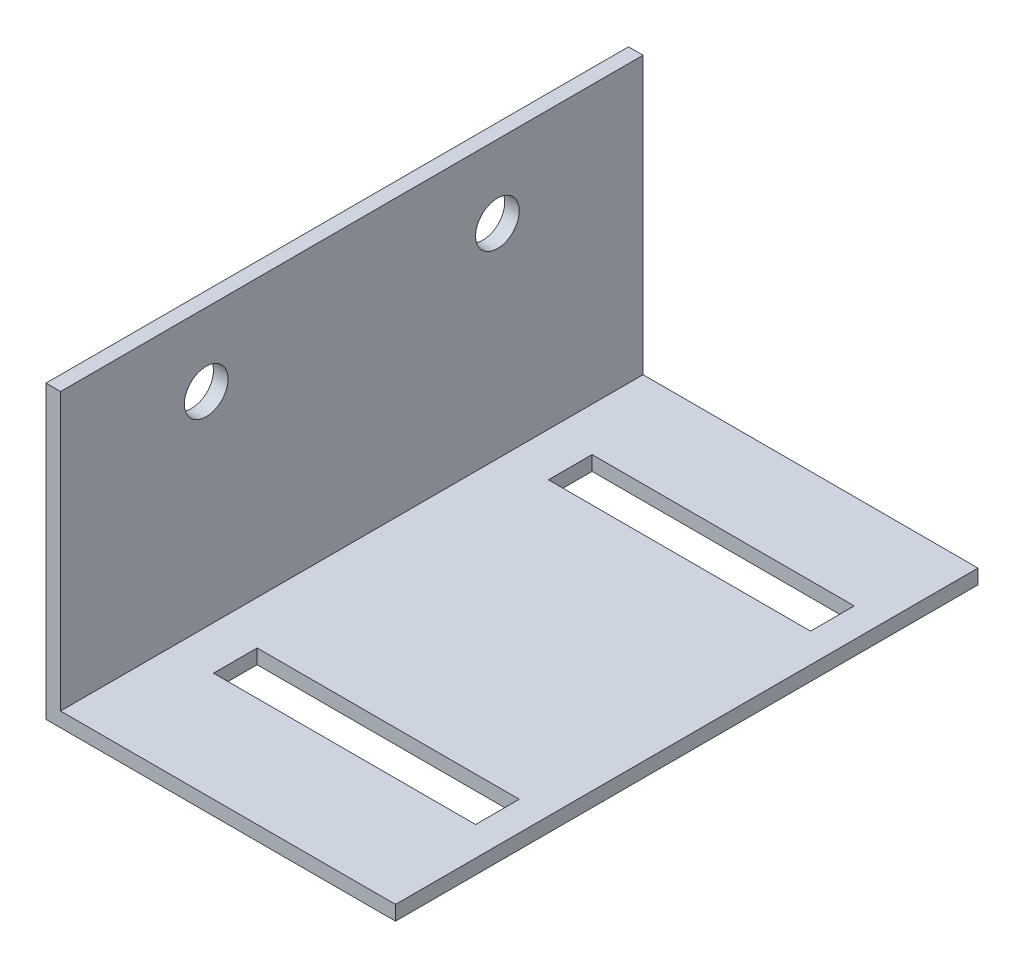
from build123d import *

# Parameters (mm, degrees)
BOSS_EXTRUDE1_DEPTH = 40
SKETCH2_W           = 18
SKETCH2_H           = 3
CUT_EXTRUDE1_DEPTH  = 10
SKETCH3_R           = 1.5
CUT_EXTRUDE2_DEPTH  = 10


with BuildPart() as part:
    # Sketch1 → Boss-Extrude1 (new body)
    with BuildSketch(Plane.XY):
        Polygon((0, 0), (24, 0), (24, 1), (1, 1), (1, 20), (0, 20), align=None)
    extrude(amount=BOSS_EXTRUDE1_DEPTH)

    # Sketch2 → Cut-Extrude1 (cut)
    with BuildSketch(Plane(origin=(0, 1, 0), x_dir=(1, 0, 0), z_dir=(0, 1, 0))):
        with Locations((13, -8)):
            Rectangle(SKETCH2_W, SKETCH2_H)
        with Locations((13, -31)):
            Rectangle(SKETCH2_W, SKETCH2_H)
    extrude(amount=-CUT_EXTRUDE1_DEPTH, mode=Mode.SUBTRACT)

    # Sketch3 → Cut-Extrude2 (cut)
    with BuildSketch(Plane.ZY):
        with Locations((30, 15)):
            Circle(SKETCH3_R)
        with Locations((10, 15)):
            Circle(SKETCH3_R)
    extrude(amount=-CUT_EXTRUDE2_DEPTH, mode=Mode.SUBTRACT)


solid = part.part
